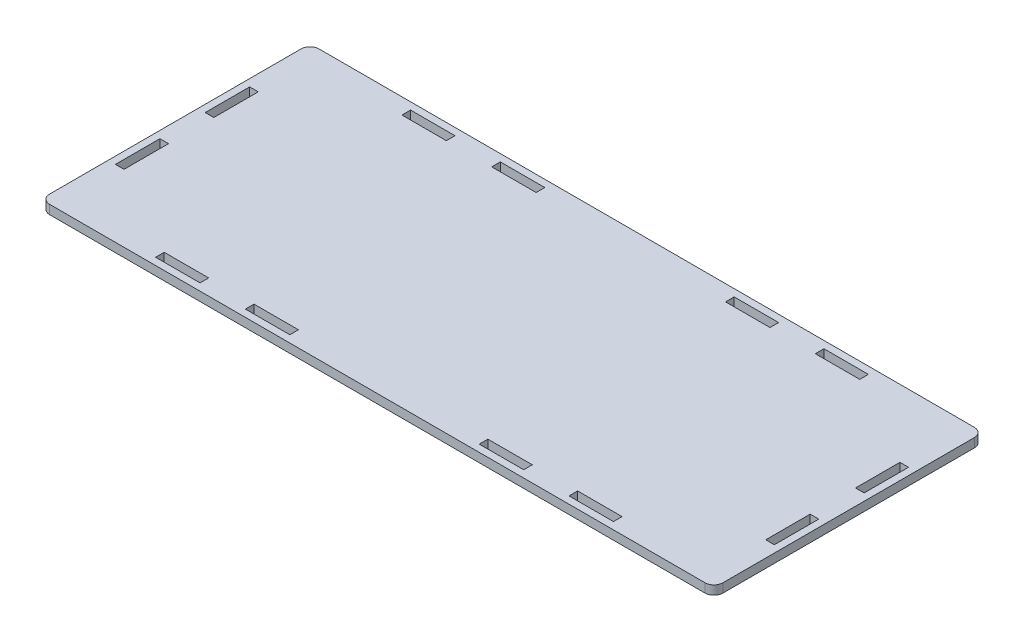
from build123d import *

# Parameters (mm, degrees)
SKETCH1_W           = 750
SKETCH1_H           = 300
BOSS_EXTRUDE1_DEPTH = 10
SKETCH4_W           = 9.6
SKETCH4_H           = 49.5
SKETCH4_W_2         = 49.5
SKETCH4_H_2         = 9.6
CUT_EXTRUDE3_DEPTH  = 11
FILLET1_R           = 10


with BuildPart() as part:
    # Sketch1 → Boss-Extrude1 (new body)
    with BuildSketch(Plane(origin=(0, 0, 0), x_dir=(1, 0, 0), z_dir=(0, 1, 0))):
        with Locations((375, 150)):
            Rectangle(SKETCH1_W, SKETCH1_H)
    extrude(amount=BOSS_EXTRUDE1_DEPTH)

    # Sketch4 → Cut-Extrude3 (cut, through all)
    with BuildSketch(Plane(origin=(0, 10, 0), x_dir=(1, 0, 0), z_dir=(0, 1, 0))):
        with Locations((12.8, 100)):
            Rectangle(SKETCH4_W, SKETCH4_H)
        with Locations((12.8, 200)):
            Rectangle(SKETCH4_W, SKETCH4_H)
        with Locations((737.2, 200)):
            Rectangle(SKETCH4_W, SKETCH4_H)
        with Locations((737.2, 100)):
            Rectangle(SKETCH4_W, SKETCH4_H)
        with Locations((144.75, 287.2)):
            Rectangle(SKETCH4_W_2, SKETCH4_H_2)
        with Locations((244.75, 287.2)):
            Rectangle(SKETCH4_W_2, SKETCH4_H_2)
        with Locations((505.25, 287.2)):
            Rectangle(SKETCH4_W_2, SKETCH4_H_2)
        with Locations((605.25, 287.2)):
            Rectangle(SKETCH4_W_2, SKETCH4_H_2)
        with Locations((605.25, 12.8)):
            Rectangle(SKETCH4_W_2, SKETCH4_H_2)
        with Locations((505.25, 12.8)):
            Rectangle(SKETCH4_W_2, SKETCH4_H_2)
        with Locations((244.75, 12.8)):
            Rectangle(SKETCH4_W_2, SKETCH4_H_2)
        with Locations((144.75, 12.8)):
            Rectangle(SKETCH4_W_2, SKETCH4_H_2)
    extrude(amount=-CUT_EXTRUDE3_DEPTH, mode=Mode.SUBTRACT)

    # Fillet1
    fillet1_edges = [part.edges().sort_by_distance(p)[0] for p in [
        (0, 5, 0),
        (750, 5, 0),
        (750, 5, -300),
        (0, 5, -300),
    ]]
    fillet(fillet1_edges, radius=FILLET1_R)


solid = part.part
